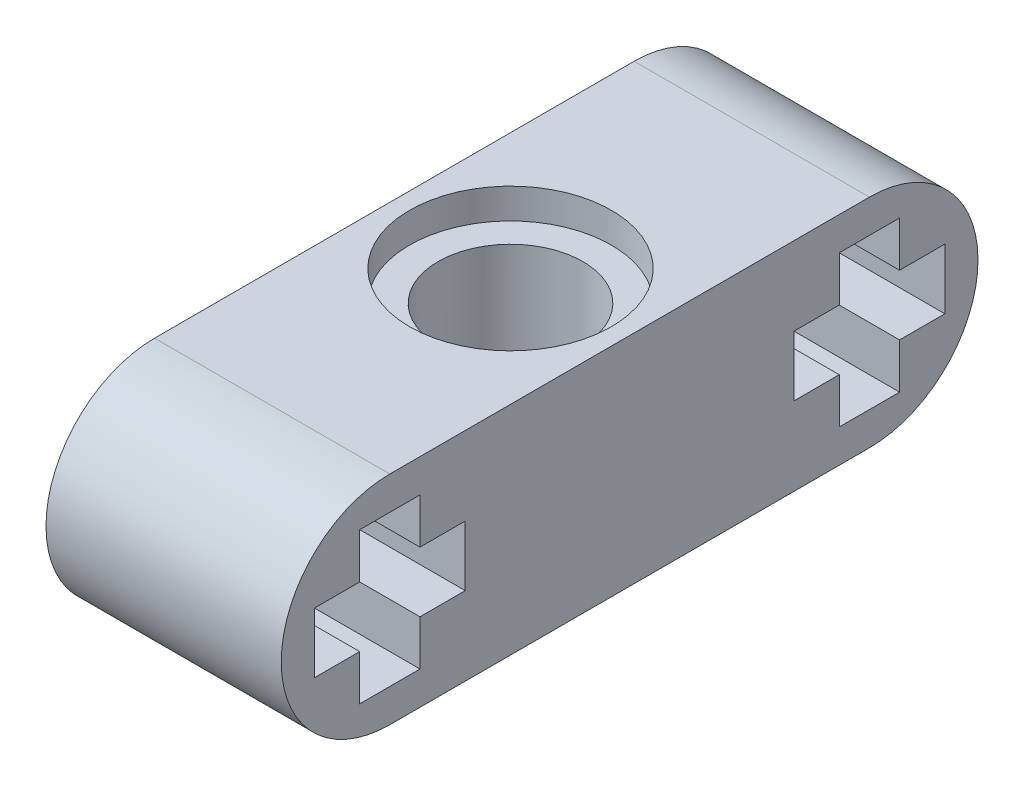
from build123d import *

# Parameters (mm, degrees)
BOSS_EXTRUDE1_DEPTH = 7.8
SKETCH3_R           = 2.4
CUT_EXTRUDE1_DEPTH  = 7.2
SKETCH6_R           = 3.345382302
SKETCH6_R_2         = 2.4
CUT_EXTRUDE3_DEPTH  = 1


with BuildPart() as part:
    # Sketch1 → Boss-Extrude1 (new body)
    with BuildSketch(Plane(origin=(0, 0, 0), x_dir=(0, 0, -1), z_dir=(1, 0, 0))):
        with BuildLine():
            Line((0, -3.6), (-15.9, -3.6))
            ThreePointArc((-15.9, -3.6), (-19.5, 0), (-15.9, 3.6))
            Line((-15.9, 3.6), (0, 3.6))
            ThreePointArc((0, 3.6), (3.6, 0), (0, -3.6))
        make_face()
        Polygon((-2.5, -1), (-1, -1), (-1, -2.5), (1, -2.5), (1, -1), (2.5, -1), (2.5, 1), (1, 1), (1, 2.5), (-1, 2.5), (-1, 1), (-2.5, 1), align=None, mode=Mode.SUBTRACT)
        Polygon((-13.4, -1), (-13.4, 1), (-14.9, 1), (-14.9, 2.5), (-16.9, 2.5), (-16.9, 1), (-18.4, 1), (-18.4, -1), (-16.9, -1), (-16.9, -2.5), (-14.9, -2.5), (-14.9, -1), align=None, mode=Mode.SUBTRACT)
    extrude(amount=BOSS_EXTRUDE1_DEPTH)

    # Sketch3 → Cut-Extrude1 (cut)
    with BuildSketch(Plane(origin=(0, 3.6, 0), x_dir=(1, 0, 0), z_dir=(0, 1, 0))):
        with Locations((3.9, -8)):
            Circle(SKETCH3_R)
    extrude(amount=-CUT_EXTRUDE1_DEPTH, mode=Mode.SUBTRACT)

    # Sketch6 → Cut-Extrude3 (cut)
    with BuildSketch(Plane(origin=(0, 3.6, 0), x_dir=(1, 0, 0), z_dir=(0, 1, 0))):
        with Locations((3.9, -8)):
            Circle(SKETCH6_R)
        with Locations((3.9, -8)):
            Circle(SKETCH6_R_2, mode=Mode.SUBTRACT)
    cut_extrude3 = extrude(amount=-CUT_EXTRUDE3_DEPTH, mode=Mode.SUBTRACT)

    # Mirror1: Cut-Extrude3 across plane
    add(cut_extrude3.mirror(Plane(origin=(0, 0, 0), x_dir=(0, 0, 1), z_dir=(0, -1, 0))), mode=Mode.SUBTRACT)


solid = part.part
